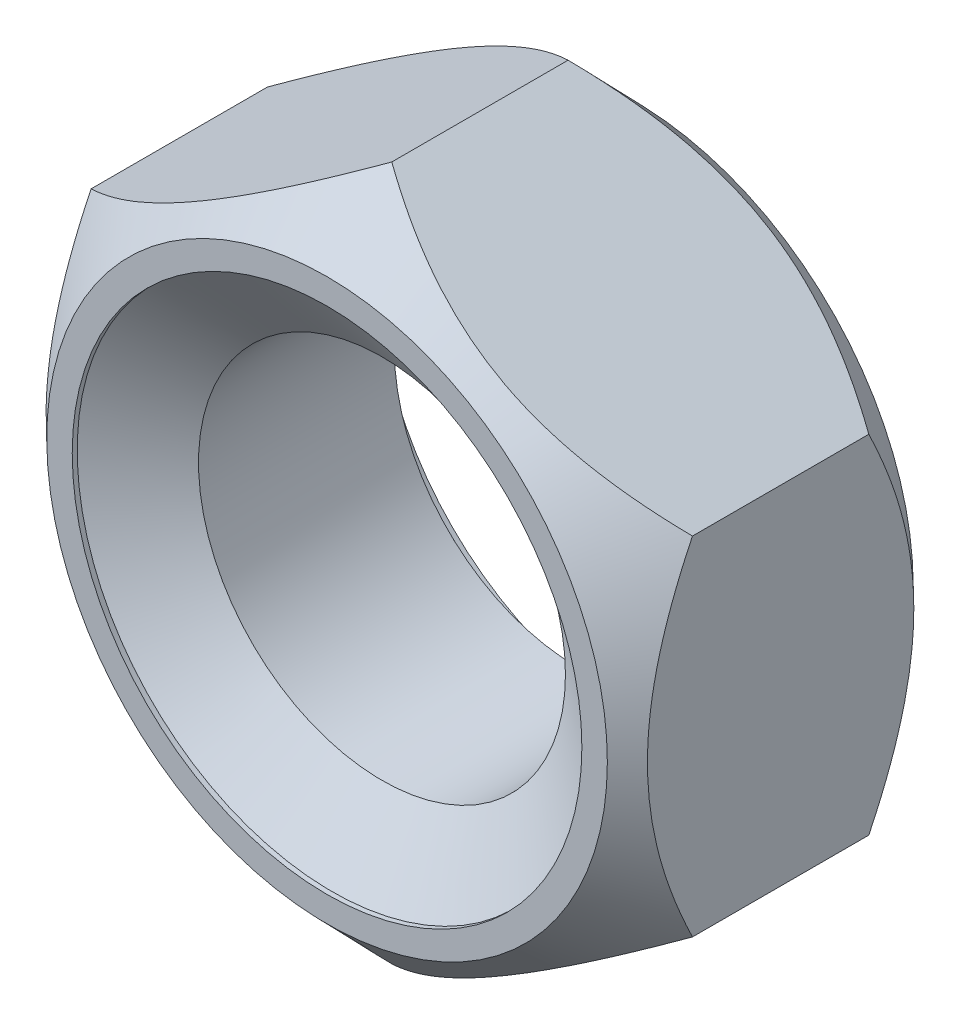
from build123d import *

# Parameters (mm, degrees)
BASENUTSKE_R  = 1.8
BASENUT_DEPTH = 3


with BuildPart() as part:
    # BaseNutSke → BaseNut (new body)
    with BuildSketch(Plane.XY):
        Polygon((2.95, 1.703183294), (2.95, -1.703183294), (0, -3.406366588), (-2.95, -1.703183294), (-2.95, 1.703183294), (0, 3.406366588), align=None)
        Circle(BASENUTSKE_R, mode=Mode.SUBTRACT)
    extrude(amount=-BASENUT_DEPTH)

    # Sketch3 → Double-Chamfer (revolve, cut)
    with BuildSketch(Plane(origin=(0, 0, 0), x_dir=(0, 0, -1), z_dir=(1, 0, 0))):
        Polygon((3, 2.75), (2.365, 3.406366588), (2.365, 16.106366588), (15.7, 16.106366588), (15.7, 2.75), align=None)
        Polygon((0.635, 16.106366588), (-12.7, 16.106366588), (-12.7, 2.75), (0, 2.75), (0.635, 3.406366588), align=None)
    revolve(axis=Axis((0, 0, 0), (0, 0, -1)), mode=Mode.SUBTRACT)

    # Sketch5 → EndChamfer (revolve, cut)
    with BuildSketch(Plane(origin=(0, 0, 0), x_dir=(0, 0, -1), z_dir=(1, 0, 0))):
        Polygon((2.9502, 2.5), (1.891136098, 0.9875), (3.001, 0.9875), (3.001, 2.5), align=None)
        Polygon((-0.002, 2.5), (0.0488, 2.5), (1.107863902, 0.9875), (-0.002, 0.9875), align=None)
    revolve(axis=Axis((0, 0, -25.037505729), (0, 0, -1)), mode=Mode.SUBTRACT)


solid = part.part
